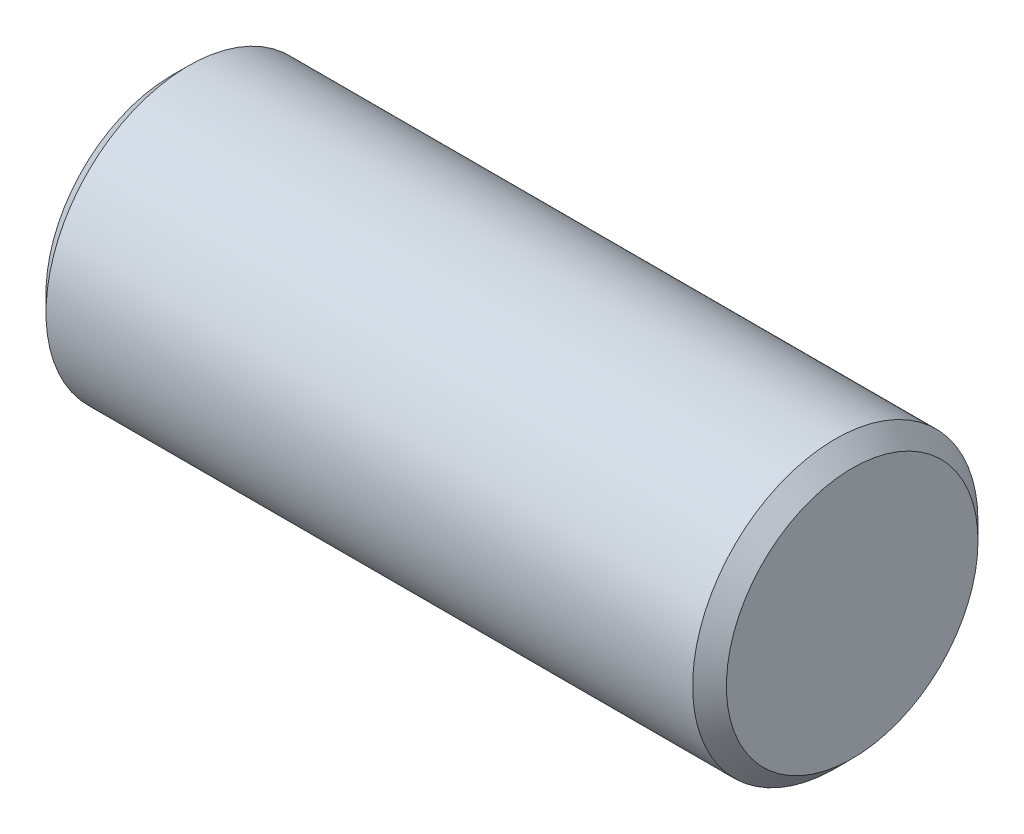
from build123d import *

# Parameters (mm, degrees)
SKETCH14_R          = 16.9
BOSS_EXTRUDE1_DEPTH = 82
CHAMFER1_SIZE       = 2


with BuildPart() as part:
    # Sketch14 → Boss-Extrude1 (new body)
    with BuildSketch(Plane(origin=(0, 0, 0), x_dir=(0, 0, -1), z_dir=(1, 0, 0))):
        Circle(SKETCH14_R)
    extrude(amount=BOSS_EXTRUDE1_DEPTH)

    # Sketch16 → Cut-Revolve4 (revolve, cut)
    with BuildSketch(Plane(origin=(0, 0, 0), x_dir=(1, 0, 0), z_dir=(0, 1, 0))):
        Polygon((1.414213562, 16.9), (1.414213562, 0), (0, 0), (0, 15.485786438), align=None)
    revolve(axis=Axis((82, 0, 0), (-1, 0, 0)), mode=Mode.SUBTRACT)


with BuildPart() as body_2:
    # of the pieces the cut leaves, the one that is kept (cut_revolve4_keep)
    add(part.part.solids().sort_by_distance((82, 0, -16.9))[0])

    # Chamfer1
    chamfer1_edges = [body_2.edges().sort_by_distance(p)[0] for p in [
        (82, 0, 16.9),
        (1.414213562, 0, 16.9),
    ]]
    chamfer(chamfer1_edges, length=CHAMFER1_SIZE)


solid = body_2.part
